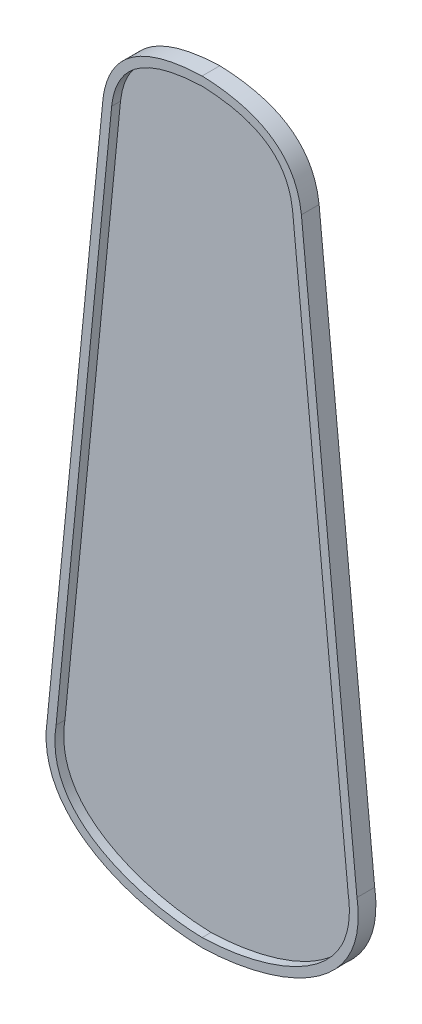
from build123d import *

# Parameters (mm, degrees)
BOSS_EXTRUDE1_DEPTH = 19.05
CUT_EXTRUDE1_DEPTH  = 9.525


with BuildPart() as part:
    # Sketch2 → Boss-Extrude1 (new body)
    with BuildSketch(Plane.XY):
        with BuildLine():
            Line((-166.6875, 130.175), (-106.876080835, 736.833680097))
            add(Edge.make_bspline(
                [(-106.876080835, 736.833680097), (-98.655564568, 809.385111394), (0, 812.8)],
                knots=[0, 0, 0, 1, 1, 1], degree=2))
            add(Edge.make_bspline(
                [(106.876080835, 736.833680097), (98.655564568, 809.385111394), (0, 812.8)],
                knots=[0, 0, 0, 1, 1, 1], degree=2))
            Line((106.876080835, 736.833680097), (166.6875, 130.175))
            add(Edge.make_bspline(
                [(0, 0), (73.666580622, 1.740675992), (181.188092361, 36.200835609), (166.6875, 130.175)],
                knots=[0, 0, 0, 0, 1, 1, 1, 1], degree=3))
            add(Edge.make_bspline(
                [(0, 0), (-73.666580622, 1.740675992), (-181.188092361, 36.200835609), (-166.6875, 130.175)],
                knots=[0, 0, 0, 0, 1, 1, 1, 1], degree=3))
        make_face()
    extrude(amount=BOSS_EXTRUDE1_DEPTH)

    # Sketch4 → Cut-Extrude1 (cut)
    with BuildSketch(Plane.XY.offset(19.05)):
        with BuildLine():
            Line((-97.403993572, 735.828587026), (-157.234081882, 128.980548454))
            add(Edge.make_bspline(
                [(-157.234081882, 128.980548454), (-157.324205492, 128.396483281), (-157.412089483, 127.812410477), (-157.576084777, 126.644224751), (-157.653279282, 126.06011552), (-157.870174292, 124.307737773), (-157.995189913, 123.139419215), (-158.309135667, 119.634255327), (-158.437031706, 117.29720201), (-158.555423917, 110.285138008), (-158.282055898, 105.60922815), (-157.411253292, 99.762537833), (-157.210017909, 98.591234632), (-156.757264158, 96.273926752), (-156.001688417, 92.827229864), (-155.017022207, 89.468234028), (-152.743005414, 82.866882475), (-150.82076111, 78.621496729), (-147.913058291, 73.508050792), (-147.306271331, 72.4950265), (-146.042259928, 70.488286534), (-145.389757898, 69.50206831), (-143.374427295, 66.59388241), (-141.953452439, 64.721702461), (-137.477795564, 59.288190671), (-134.211225834, 55.909160224), (-129.824716649, 51.946319201), (-128.932947118, 51.167642375), (-127.132093683, 49.645344246), (-126.221588539, 48.900422844), (-123.461599805, 46.711504594), (-121.583697089, 45.313266475), (-115.848105381, 41.282598746), (-111.889088448, 38.81332115), (-103.746143975, 34.236903166), (-99.561981891, 32.130140428), (-94.209825099, 29.693050126), (-93.132197949, 29.215042748), (-90.971456085, 28.280905266), (-89.888342715, 27.824742202), (-86.631139254, 26.48752268), (-84.44919675, 25.6376924), (-77.874418426, 23.203328361), (-73.452755763, 21.733428424), (-64.541987933, 19.061822744), (-60.052845479, 17.860265278), (-51.012964961, 15.702093584), (-46.462212797, 14.745535421), (-37.302169602, 13.065206786), (-32.692883998, 12.341414728), (-25.735345382, 11.429148513), (-23.408876198, 11.154048031), (-18.7411174, 10.662782498), (-16.401859715, 10.446870289), (-9.382680965, 9.891490593), (-4.695544036, 9.643012505), (0, 9.52776174)],
                knots=[0, 0, 0, 0, 0.0078125, 0.0078125, 0.015625, 0.015625, 0.03125, 0.03125, 0.0625, 0.0625, 0.125, 0.125, 0.140625, 0.140625, 0.15625, 0.1875, 0.1875, 0.25, 0.25, 0.265625, 0.265625, 0.28125, 0.28125, 0.3125, 0.3125, 0.375, 0.375, 0.390625, 0.390625, 0.40625, 0.40625, 0.4375, 0.4375, 0.5, 0.5, 0.5625, 0.5625, 0.578125, 0.578125, 0.59375, 0.59375, 0.625, 0.625, 0.6875, 0.6875, 0.75, 0.75, 0.8125, 0.8125, 0.875, 0.875, 0.90625, 0.90625, 0.9375, 0.9375, 1, 1, 1, 1], degree=3))
            add(Edge.make_bspline(
                [(0, 9.52776174), (4.696782429, 9.643042901), (9.371788605, 9.891241348), (18.682630774, 10.626724118), (23.318416438, 11.114315633), (32.552071373, 12.320931698), (37.149923971, 13.040058014), (46.306955275, 14.714367272), (50.866134292, 15.669548315), (59.943247261, 17.831660883), (64.461195673, 19.038504147), (71.20372728, 21.058683944), (73.447300549, 21.767866857), (77.898983356, 23.253348365), (80.109631224, 24.030343068), (86.693442252, 26.469842463), (91.018725741, 28.240292259), (99.522601409, 32.111908605), (103.70134125, 34.212742248), (108.81530232, 37.085571172), (109.832590209, 37.672546502), (111.855568511, 38.872643767), (112.862320589, 39.486453403), (115.852002601, 41.361553617), (117.806717627, 42.657699597), (123.546532273, 46.69530685), (127.208159374, 49.584908122), (132.403942543, 54.275234083), (134.0862339, 55.898228847), (136.526821296, 58.432122427), (137.326523938, 59.293342382), (138.896628692, 61.050936516), (139.668584954, 61.949275112), (143.422485376, 66.499587265), (146.099261927, 70.337793886), (149.575356296, 76.4220986), (150.644084323, 78.504775138), (152.10493938, 81.715069485), (152.568177575, 82.799551968), (153.44592623, 84.998074695), (153.858285185, 86.106992021), (155.77907965, 91.670668847), (156.87633236, 96.211033443), (157.917859106, 103.144578031), (158.164237879, 105.476273711), (158.388791016, 109.003330668), (158.439487754, 110.186052077), (158.493329725, 112.548388418), (158.496596004, 113.728050186), (158.438962094, 117.262741174), (158.31071539, 119.613481568), (157.996011579, 123.131801583), (157.87069881, 124.303275057), (157.58107101, 126.643738225), (157.414305379, 127.812571858), (157.234081882, 128.980548454)],
                knots=[0, 0, 0, 0, 0.0625, 0.0625, 0.125, 0.125, 0.1875, 0.1875, 0.25, 0.25, 0.3125, 0.3125, 0.34375, 0.34375, 0.375, 0.375, 0.4375, 0.4375, 0.5, 0.5, 0.515625, 0.515625, 0.53125, 0.53125, 0.5625, 0.5625, 0.625, 0.625, 0.65625, 0.65625, 0.671875, 0.671875, 0.6875, 0.6875, 0.75, 0.75, 0.78125, 0.78125, 0.796875, 0.796875, 0.8125, 0.8125, 0.875, 0.875, 0.90625, 0.90625, 0.921875, 0.921875, 0.9375, 0.9375, 0.96875, 0.96875, 0.984375, 0.984375, 1, 1, 1, 1], degree=3))
            Line((157.234081882, 128.980548454), (97.403993572, 735.828587022))
            add(Edge.make_bspline(
                [(97.403993572, 735.828587022), (97.092286958, 738.562982934), (96.669418738, 741.267379451), (95.570059645, 746.607726854), (94.893642768, 749.243697709), (93.247932944, 754.436600394), (92.278730315, 756.993556598), (90.853060681, 760.13195437), (90.557097177, 760.756799005), (89.94756396, 761.991267361), (89.633481965, 762.602053668), (88.66308079, 764.414924295), (87.978602457, 765.597517573), (85.810987946, 769.066265293), (84.213589669, 771.273330454), (81.584120863, 774.422394534), (80.668756062, 775.44517415), (79.236968861, 776.938685261), (78.749736274, 777.429849509), (77.763144525, 778.391567332), (77.262906247, 778.863062984), (72.700160744, 783.024790933), (68.215938322, 786.146253506), (62.187228676, 789.476997053), (60.964200371, 790.112025219), (58.502000457, 791.317342862), (57.260396611, 791.888985895), (53.506907039, 793.519234755), (50.966447444, 794.493467918), (43.248745942, 797.131746553), (37.976068957, 798.513992185), (31.266175529, 799.890277732), (29.917456906, 800.147831744), (27.218689157, 800.627892818), (25.867458716, 800.850662293), (21.808637288, 801.471016253), (19.095929317, 801.820768942), (10.940039087, 802.703953619), (5.479213552, 803.072462364), (2e-09, 803.26908628)],
                knots=[0, 0, 0, 0, 0.0625, 0.0625, 0.125, 0.125, 0.1875, 0.1875, 0.203125, 0.203125, 0.21875, 0.21875, 0.25, 0.25, 0.3125, 0.3125, 0.34375, 0.34375, 0.359375, 0.359375, 0.375, 0.375, 0.5, 0.5, 0.53125, 0.53125, 0.5625, 0.5625, 0.625, 0.625, 0.75, 0.75, 0.78125, 0.78125, 0.8125, 0.8125, 0.875, 0.875, 1, 1, 1, 1], degree=3))
            add(Edge.make_bspline(
                [(2e-09, 803.26908628), (-5.471123606, 803.072752675), (-10.913888363, 802.705230434), (-21.727709567, 801.537317666), (-27.098938668, 800.737969365), (-35.084786769, 799.110381206), (-37.734826452, 798.495958833), (-43.006804741, 797.097481507), (-45.628764384, 796.313553549), (-49.536321772, 794.984442323), (-50.832509452, 794.516370139), (-53.395578467, 793.531913824), (-54.664623053, 793.014810614), (-58.431517441, 791.383359846), (-60.889276194, 790.189166552), (-65.679911837, 787.552063988), (-68.012848984, 786.109274725), (-72.530602319, 782.928697006), (-74.672229275, 781.220279014), (-78.696640654, 777.560904851), (-80.581086505, 775.608725668), (-83.205841084, 772.486867934), (-84.047113279, 771.413989968), (-85.660763906, 769.202180872), (-86.433815235, 768.062175102), (-90.116138831, 762.204478677), (-92.353845254, 757.218061553), (-94.440219005, 750.683674858), (-94.821772855, 749.361651688), (-95.517065206, 746.688851322), (-95.829087041, 745.344622952), (-96.665508178, 741.295731389), (-97.091208587, 738.572442767), (-97.403993572, 735.828587026)],
                knots=[0, 0, 0, 0, 0.125, 0.125, 0.25, 0.25, 0.3125, 0.3125, 0.375, 0.375, 0.40625, 0.40625, 0.4375, 0.4375, 0.5, 0.5, 0.5625, 0.5625, 0.625, 0.625, 0.6875, 0.6875, 0.71875, 0.71875, 0.75, 0.75, 0.875, 0.875, 0.90625, 0.90625, 0.9375, 0.9375, 1, 1, 1, 1], degree=3))
        make_face()
    extrude(amount=-CUT_EXTRUDE1_DEPTH, mode=Mode.SUBTRACT)


solid = part.part
